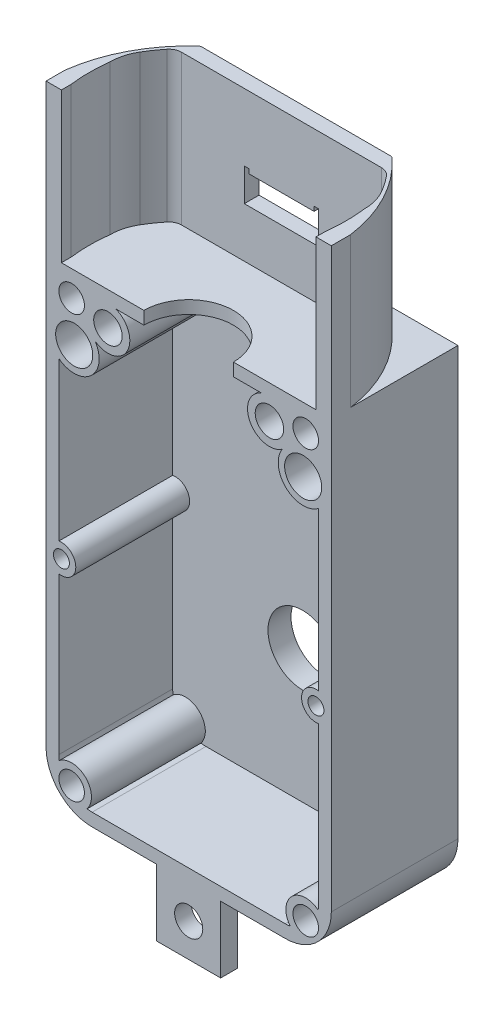
from build123d import *

# Parameters (mm, degrees)
SKETCH1_R           = 1
SKETCH1_R_2         = 0.625
SKETCH1_R_3         = 2.7
SKETCH1_R_4         = 1.45
SKETCH1_R_5         = 1.112325309
BOSS_EXTRUDE1_DEPTH = 1
SKETCH2_R           = 1.112325309
SKETCH2_R_2         = 1.45
SKETCH2_R_3         = 0.625
SKETCH2_R_4         = 1
BOSS_EXTRUDE2_DEPTH = 9.9
BOSS_EXTRUDE3_DEPTH = 1.55
SKETCH4_R           = 2.2
CUT_EXTRUDE1_DEPTH  = 2.1
SKETCH5_R           = 3.55
SKETCH5_R_2         = 2.7
BOSS_EXTRUDE4_DEPTH = 0.8
SKETCH6_R           = 2.05
BOSS_EXTRUDE5_DEPTH = 2.4
SKETCH7_W           = 5
SKETCH7_H           = 5.2
SKETCH7_R           = 1.1
BOSS_EXTRUDE6_DEPTH = 1.3
CUT_EXTRUDE2_DEPTH  = 1.3
BOSS_EXTRUDE7_DEPTH = 11.7
CUT_EXTRUDE3_DEPTH  = 1.7
SKETCH11_W          = 5.1
SKETCH11_H          = 1.6
BOSS_EXTRUDE8_DEPTH = 3
SKETCH12_W          = 5.1
SKETCH12_H          = 1
BOSS_EXTRUDE9_DEPTH = 2.5
SKETCH13_R          = 1
CUT_EXTRUDE4_DEPTH  = 2.5
FILLET1_R           = 0.3
FILLET2_R           = 0.3


with BuildPart() as part:
    # Sketch1 → Boss-Extrude1 (new body)
    with BuildSketch(Plane.XY):
        with BuildLine():
            Line((-7.55, -18.5), (7.55, -18.5))
            ThreePointArc((7.55, -18.5), (10.095584412, -17.445584412), (11.15, -14.9))
            Line((11.15, -14.9), (11.15, 18.5))
            Line((11.15, 18.5), (-11.15, 18.5))
            Line((-11.15, 18.5), (-11.15, -14.9))
            ThreePointArc((-11.15, -14.9), (-10.095584412, -17.445584412), (-7.55, -18.5))
        make_face()
        with Locations((9.15, -16.5)):
            Circle(SKETCH1_R, mode=Mode.SUBTRACT)
        with Locations((-9.95, -1.55)):
            Circle(SKETCH1_R_2, mode=Mode.SUBTRACT)
        with Locations((9.95, -1.55)):
            Circle(SKETCH1_R_2, mode=Mode.SUBTRACT)
        with Locations((-9.15, -16.5)):
            Circle(SKETCH1_R, mode=Mode.SUBTRACT)
        with Locations((0, -7.2)):
            Circle(SKETCH1_R_3, mode=Mode.SUBTRACT)
        with Locations((9.15, 16.5)):
            Circle(SKETCH1_R, mode=Mode.SUBTRACT)
        with Locations((-9.15, 16.5)):
            Circle(SKETCH1_R, mode=Mode.SUBTRACT)
        with Locations((8.95, 13.456564441)):
            Circle(SKETCH1_R_4, mode=Mode.SUBTRACT)
        with Locations((6.312747808, 15.9)):
            Circle(SKETCH1_R_5, mode=Mode.SUBTRACT)
        with Locations((-6.312747808, 15.9)):
            Circle(SKETCH1_R_5, mode=Mode.SUBTRACT)
        with Locations((-8.95, 13.456564441)):
            Circle(SKETCH1_R_4, mode=Mode.SUBTRACT)
    extrude(amount=BOSS_EXTRUDE1_DEPTH)

    # Sketch2 → Boss-Extrude2 (add)
    with BuildSketch(Plane.XY):
        with BuildLine():
            Line((-11.15, -14.9), (-11.15, 18.5))
            Line((-11.15, 18.5), (11.15, 18.5))
            Line((11.15, 18.5), (11.15, -14.9))
            ThreePointArc((11.15, -14.9), (10.095584412, -17.445584412), (7.55, -18.5))
            Line((7.55, -18.5), (-7.55, -18.5))
            ThreePointArc((-7.55, -18.5), (-10.095584412, -17.445584412), (-11.15, -14.9))
        make_face()
        with Locations((-6.312747808, 15.9)):
            Circle(SKETCH2_R, mode=Mode.SUBTRACT)
        with Locations((-8.95, 13.456564441)):
            Circle(SKETCH2_R_2, mode=Mode.SUBTRACT)
        with Locations((-9.95, -1.55)):
            Circle(SKETCH2_R_3, mode=Mode.SUBTRACT)
        with Locations((-9.15, -16.5)):
            Circle(SKETCH2_R_4, mode=Mode.SUBTRACT)
        with Locations((9.15, -16.5)):
            Circle(SKETCH2_R_4, mode=Mode.SUBTRACT)
        with Locations((9.95, -1.55)):
            Circle(SKETCH2_R_3, mode=Mode.SUBTRACT)
        with Locations((8.95, 13.456564441)):
            Circle(SKETCH2_R_2, mode=Mode.SUBTRACT)
        with Locations((6.312747808, 15.9)):
            Circle(SKETCH2_R, mode=Mode.SUBTRACT)
        with Locations((-9.15, 16.5)):
            Circle(SKETCH2_R_4, mode=Mode.SUBTRACT)
        with Locations((9.15, 16.5)):
            Circle(SKETCH2_R_4, mode=Mode.SUBTRACT)
        with BuildLine():
            Line((-10.15, -14.9), (-10.15, -2.657079491))
            ThreePointArc((-10.15, -2.657079491), (-8.825, -1.55), (-10.15, -0.442920509))
            Line((-10.15, -0.442920509), (-10.15, 11.919521826))
            ThreePointArc((-10.15, 11.919521826), (-7.638269734, 12.013697951), (-7.305911803, 14.505122499))
            ThreePointArc((-7.305911803, 14.505122499), (-4.803101136, 15.091900446), (-5.702782265, 17.5))
            Line((-5.702782265, 17.5), (5.702782265, 17.5))
            ThreePointArc((5.702782265, 17.5), (4.803101136, 15.091900446), (7.305911803, 14.505122499))
            ThreePointArc((7.305911803, 14.505122499), (7.638269734, 12.013697951), (10.15, 11.919521826))
            Line((10.15, 11.919521826), (10.15, -0.442920509))
            ThreePointArc((10.15, -0.442920509), (8.825, -1.55), (10.15, -2.657079491))
            Line((10.15, -2.657079491), (10.15, -14.9))
            ThreePointArc((10.15, -14.9), (10.142584462, -15.096228972), (10.120380146, -15.291338604))
            ThreePointArc((10.120380146, -15.291338604), (8.053984489, -15.403984489), (7.941338604, -17.470380146))
            ThreePointArc((7.941338604, -17.470380146), (7.746228972, -17.492584462), (7.55, -17.5))
            Line((7.55, -17.5), (-7.55, -17.5))
            ThreePointArc((-7.55, -17.5), (-7.746228972, -17.492584462), (-7.941338604, -17.470380146))
            ThreePointArc((-7.941338604, -17.470380146), (-8.053984489, -15.403984489), (-10.120380146, -15.291338604))
            ThreePointArc((-10.120380146, -15.291338604), (-10.142584462, -15.096228972), (-10.15, -14.9))
        make_face(mode=Mode.SUBTRACT)
    extrude(amount=BOSS_EXTRUDE2_DEPTH)

    # Sketch3 → Boss-Extrude3 (add)
    with BuildSketch(Plane.XY.offset(1)):
        with BuildLine():
            Line((5.702782265, 17.5), (4.327174843, 17.5))
            ThreePointArc((4.327174843, 17.5), (4.183564019, 14.496762175), (7.000038147, 13.444367293))
            ThreePointArc((7.000038147, 13.444367293), (7.076340654, 13.996842756), (7.305911803, 14.505122499))
            ThreePointArc((7.305911803, 14.505122499), (4.803101136, 15.091900446), (5.702782265, 17.5))
        make_face()
        with BuildLine():
            Line((-4.327174843, 17.5), (-5.702782265, 17.5))
            ThreePointArc((-5.702782265, 17.5), (-4.803101136, 15.091900446), (-7.305911803, 14.505122499))
            ThreePointArc((-7.305911803, 14.505122499), (-7.076340654, 13.996842756), (-7.000038147, 13.444367293))
            ThreePointArc((-7.000038147, 13.444367293), (-4.183564019, 14.496762175), (-4.327174843, 17.5))
        make_face()
    extrude(amount=BOSS_EXTRUDE3_DEPTH)

    # Sketch4 → Cut-Extrude1 (cut)
    with BuildSketch(Plane(origin=(0, 0, 0), x_dir=(-1, 0, 0), z_dir=(0, 0, -1))):
        with Locations((-6.312747808, 15.9)):
            Circle(SKETCH4_R)
        with Locations((6.312747808, 15.9)):
            Circle(SKETCH4_R)
    extrude(amount=-CUT_EXTRUDE1_DEPTH, mode=Mode.SUBTRACT)

    # Sketch5 → Boss-Extrude4 (add)
    with BuildSketch(Plane(origin=(0, 0, 0), x_dir=(-1, 0, 0), z_dir=(0, 0, -1))):
        with Locations((0, -7.2)):
            Circle(SKETCH5_R)
        with Locations((0, -7.2)):
            Circle(SKETCH5_R_2, mode=Mode.SUBTRACT)
    extrude(amount=BOSS_EXTRUDE4_DEPTH)

    # Sketch6 → Boss-Extrude5 (add)
    with BuildSketch(Plane(origin=(0, 0, 0), x_dir=(-1, 0, 0), z_dir=(0, 0, -1))):
        with Locations((0, 4.45)):
            Circle(SKETCH6_R)
    extrude(amount=BOSS_EXTRUDE5_DEPTH)

    # Sketch7 → Boss-Extrude6 (add)
    with BuildSketch(Plane.XY.offset(9.9)):
        with Locations((0, -21.1)):
            Rectangle(SKETCH7_W, SKETCH7_H)
        with Locations((0, -21.1)):
            Circle(SKETCH7_R, mode=Mode.SUBTRACT)
    extrude(amount=-BOSS_EXTRUDE6_DEPTH)

    # Sketch8 → Cut-Extrude2 (cut)
    with BuildSketch(Plane(origin=(0, 18.5, 0), x_dir=(1, 0, 0), z_dir=(0, 1, 0))):
        with BuildLine():
            Line((3.5, -9.9), (-3.5, -9.9))
            ThreePointArc((-3.5, -9.9), (0, -6.4), (3.5, -9.9))
        make_face()
    extrude(amount=-CUT_EXTRUDE2_DEPTH, mode=Mode.SUBTRACT)

    # Sketch9 → Boss-Extrude7 (add)
    with BuildSketch(Plane(origin=(0, 18.5, 0), x_dir=(1, 0, 0), z_dir=(0, 1, 0))):
        with BuildLine():
            Line((-9.95, -9.9), (-9.95, -9.159245706))
            ThreePointArc((-9.95, -9.159245706), (-10.047335999, -7.629787334), (-9.95, -6.100328962))
            ThreePointArc((-9.95, -6.100328962), (-9.819948204, -5.141444475), (-9.439189189, -4.251840348))
            ThreePointArc((-9.439189189, -4.251840348), (-9.033881062, -3.623934915), (-8.586872248, -3.025))
            ThreePointArc((-8.586872248, -3.025), (-8.2392602, -2.748612181), (-7.806247498, -2.65))
            Line((-7.806247498, -2.65), (7.806247498, -2.65))
            ThreePointArc((7.806247498, -2.65), (8.2392602, -2.748612181), (8.586872248, -3.025))
            ThreePointArc((8.586872248, -3.025), (9.033881062, -3.623934915), (9.439189189, -4.251840348))
            ThreePointArc((9.439189189, -4.251840348), (9.819948204, -5.141444475), (9.95, -6.100328962))
            ThreePointArc((9.95, -6.100328962), (10.047335999, -7.629787334), (9.95, -9.159245706))
            Line((9.95, -9.159245706), (9.95, -9.9))
            Line((9.95, -9.9), (11.15, -9.9))
            Line((11.15, -9.9), (11.15, -8.403337045))
            ThreePointArc((11.15, -8.403337045), (9.935576313, -4.622991063), (7.48348181, -1.5))
            Line((7.48348181, -1.5), (-7.48348181, -1.5))
            ThreePointArc((-7.48348181, -1.5), (-9.935576313, -4.622991063), (-11.15, -8.403337045))
            Line((-11.15, -8.403337045), (-11.15, -9.9))
            Line((-11.15, -9.9), (-9.95, -9.9))
        make_face()
    extrude(amount=BOSS_EXTRUDE7_DEPTH)

    # Sketch10 → Cut-Extrude3 (cut)
    with BuildSketch(Plane.XY.offset(2.65)):
        Polygon((2.55, 24.6), (-2.55, 24.6), (-2.55, 24.95), (-2.9, 24.95), (-2.9, 24.6), (-2.9, 22.4), (2.9, 22.4), (2.9, 24.6), (2.9, 24.95), (2.55, 24.95), align=None)
    extrude(amount=-CUT_EXTRUDE3_DEPTH, mode=Mode.SUBTRACT)

    # Sketch11 → Boss-Extrude8 (add)
    with BuildSketch(Plane(origin=(0, 0, 1.5), x_dir=(-1, 0, 0), z_dir=(0, 0, -1))):
        with Locations((0, 25.4)):
            Rectangle(SKETCH11_W, SKETCH11_H)
    extrude(amount=BOSS_EXTRUDE8_DEPTH)

    # Sketch12 → Boss-Extrude9 (add)
    with BuildSketch(Plane(origin=(0, 26.2, 0), x_dir=(1, 0, 0), z_dir=(0, 1, 0))):
        with Locations((0, 1)):
            Rectangle(SKETCH12_W, SKETCH12_H)
    extrude(amount=-BOSS_EXTRUDE9_DEPTH)

    # Sketch13 → Cut-Extrude4 (cut)
    with BuildSketch(Plane.XY.offset(1)):
        with Locations((0, 4.45)):
            Circle(SKETCH13_R)
    extrude(amount=-CUT_EXTRUDE4_DEPTH, mode=Mode.SUBTRACT)

    # Fillet1
    fillet1_edges = [part.edges().sort_by_distance(p)[0] for p in [
        (2.05, 4.45, -2.4),
    ]]
    fillet(fillet1_edges, radius=FILLET1_R)

    # Fillet2
    fillet2_edges = [part.edges().sort_by_distance(p)[0] for p in [
        (7.48348181, 24.35, 1.5),
        (-7.48348181, 24.35, 1.5),
    ]]
    fillet(fillet2_edges, radius=FILLET2_R)


solid = part.part
